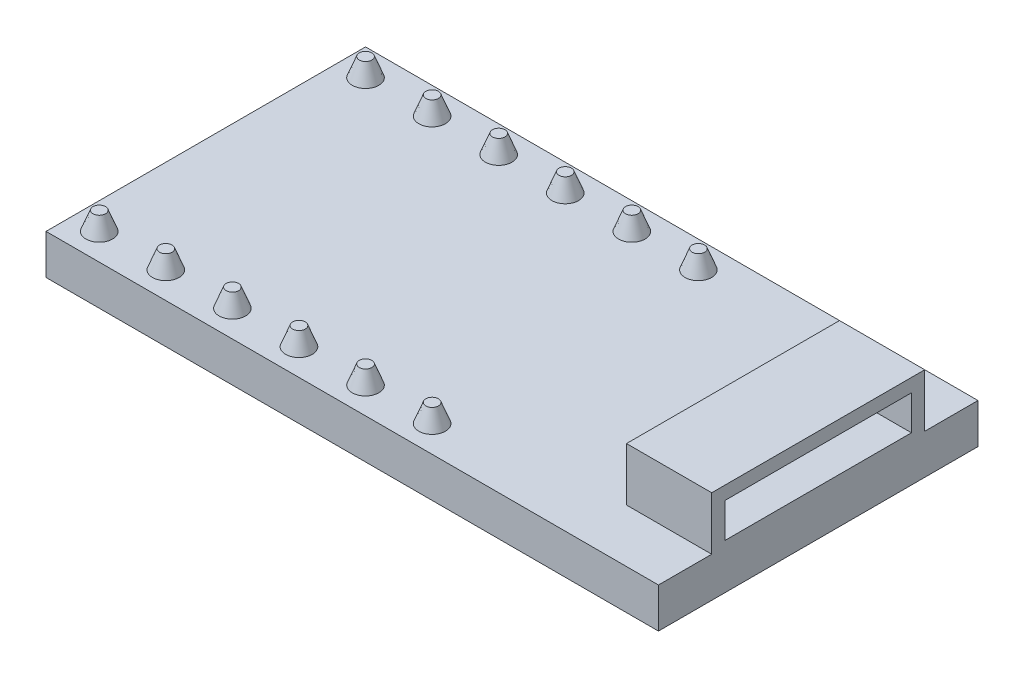
from build123d import *

# Parameters (mm, degrees)
SKETCH1_W               = 23
SKETCH1_H               = 12
BOSS_EXTRUDE1_DEPTH     = 1.5
SKETCH2_W               = 3.2
SKETCH2_H               = 8
BOSS_EXTRUDE2_DEPTH     = 2
SKETCH3_W               = 7
SKETCH3_H               = 1.3
CUT_EXTRUDE1_DEPTH      = 2.7
SKETCH4_R               = 0.5
BOSS_EXTRUDE3_DEPTH     = 0.69
BOSS_EXTRUDE3_TAPER     = 21
LPATTERN1_COUNT         = 6
LPATTERN1_PITCH         = 2.5
MIRROR1_COPY_1_SKETCH_R = 0.5
MIRROR1_COPY_1_DEPTH    = 0.69
MIRROR1_COPY_1_TAPER    = 21
MIRROR1_COPY_2_SKETCH_R = 0.5
MIRROR1_COPY_2_DEPTH    = 0.69
MIRROR1_COPY_2_TAPER    = 21
MIRROR1_COPY_3_SKETCH_R = 0.5
MIRROR1_COPY_3_DEPTH    = 0.69
MIRROR1_COPY_3_TAPER    = 21
MIRROR1_COPY_4_SKETCH_R = 0.5
MIRROR1_COPY_4_DEPTH    = 0.69
MIRROR1_COPY_4_TAPER    = 21
MIRROR1_COPY_5_SKETCH_R = 0.5
MIRROR1_COPY_5_DEPTH    = 0.69
MIRROR1_COPY_5_TAPER    = 21


with BuildPart() as part:
    # Sketch1 → Boss-Extrude1 (new body)
    with BuildSketch(Plane(origin=(0, 0, 0), x_dir=(1, 0, 0), z_dir=(0, 1, 0))):
        Rectangle(SKETCH1_W, SKETCH1_H)
    extrude(amount=BOSS_EXTRUDE1_DEPTH)

    # Sketch2 → Boss-Extrude2 (add)
    with BuildSketch(Plane(origin=(0, 1.5, 0), x_dir=(1, 0, 0), z_dir=(0, 1, 0))):
        with Locations((9.9, 0)):
            Rectangle(SKETCH2_W, SKETCH2_H)
    extrude(amount=BOSS_EXTRUDE2_DEPTH)

    # Sketch3 → Cut-Extrude1 (cut)
    with BuildSketch(Plane(origin=(11.5, 0, 0), x_dir=(0, 0, -1), z_dir=(1, 0, 0))):
        with Locations((0, 2.35)):
            Rectangle(SKETCH3_W, SKETCH3_H)
    extrude(amount=-CUT_EXTRUDE1_DEPTH, mode=Mode.SUBTRACT)

    # Sketch4 → Boss-Extrude3 (add)
    with BuildSketch(Plane(origin=(0, 1.5, 0), x_dir=(1, 0, 0), z_dir=(0, 1, 0))):
        with Locations((-10.5, 5)):
            Circle(SKETCH4_R)
    boss_extrude3 = extrude(amount=BOSS_EXTRUDE3_DEPTH, taper=BOSS_EXTRUDE3_TAPER)

    # LPattern1: Boss-Extrude3 ×6
    with Locations(*[(i * LPATTERN1_PITCH, 0, 0) for i in range(1, LPATTERN1_COUNT)]):
        add(boss_extrude3)

    # Mirror1: Boss-Extrude3 across plane
    add(boss_extrude3.mirror(Plane.XY))

    # Mirror1 copy 1 sketch → Mirror1 copy 1 (add)
    with BuildSketch(Plane(origin=(2.5, 1.5, 0), x_dir=(1, 0, 0), z_dir=(0, 1, 0))):
        with Locations((-10.5, -5)):
            Circle(MIRROR1_COPY_1_SKETCH_R)
    extrude(amount=MIRROR1_COPY_1_DEPTH, taper=MIRROR1_COPY_1_TAPER)

    # Mirror1 copy 2 sketch → Mirror1 copy 2 (add)
    with BuildSketch(Plane(origin=(5, 1.5, 0), x_dir=(1, 0, 0), z_dir=(0, 1, 0))):
        with Locations((-10.5, -5)):
            Circle(MIRROR1_COPY_2_SKETCH_R)
    extrude(amount=MIRROR1_COPY_2_DEPTH, taper=MIRROR1_COPY_2_TAPER)

    # Mirror1 copy 3 sketch → Mirror1 copy 3 (add)
    with BuildSketch(Plane(origin=(7.5, 1.5, 0), x_dir=(1, 0, 0), z_dir=(0, 1, 0))):
        with Locations((-10.5, -5)):
            Circle(MIRROR1_COPY_3_SKETCH_R)
    extrude(amount=MIRROR1_COPY_3_DEPTH, taper=MIRROR1_COPY_3_TAPER)

    # Mirror1 copy 4 sketch → Mirror1 copy 4 (add)
    with BuildSketch(Plane(origin=(10, 1.5, 0), x_dir=(1, 0, 0), z_dir=(0, 1, 0))):
        with Locations((-10.5, -5)):
            Circle(MIRROR1_COPY_4_SKETCH_R)
    extrude(amount=MIRROR1_COPY_4_DEPTH, taper=MIRROR1_COPY_4_TAPER)

    # Mirror1 copy 5 sketch → Mirror1 copy 5 (add)
    with BuildSketch(Plane(origin=(12.5, 1.5, 0), x_dir=(1, 0, 0), z_dir=(0, 1, 0))):
        with Locations((-10.5, -5)):
            Circle(MIRROR1_COPY_5_SKETCH_R)
    extrude(amount=MIRROR1_COPY_5_DEPTH, taper=MIRROR1_COPY_5_TAPER)


solid = part.part
